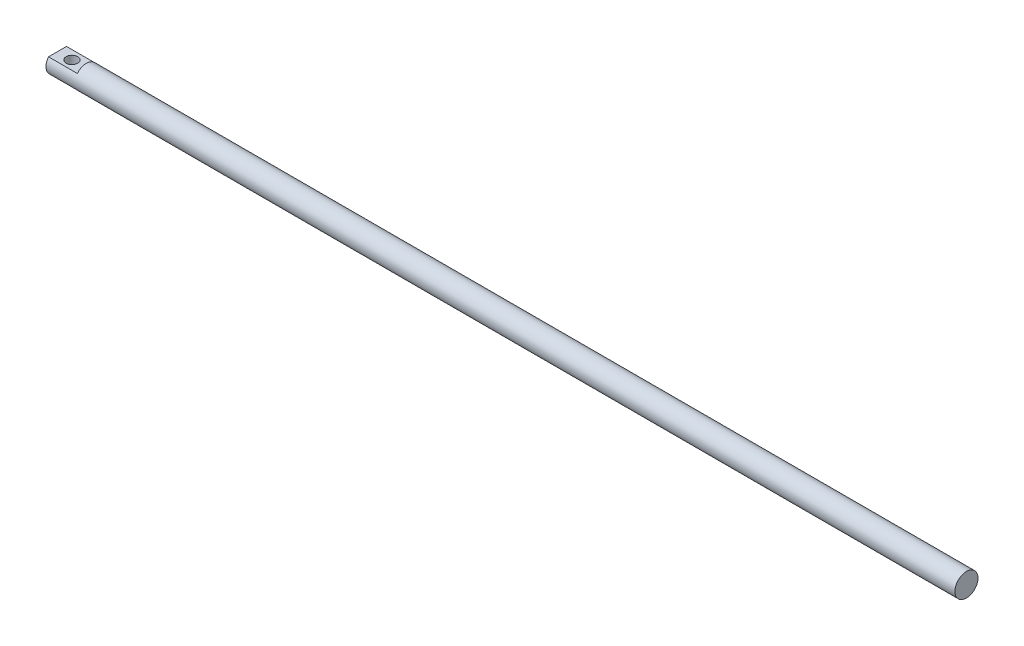
from build123d import *

# Parameters (mm, degrees)
SKETCH_1_R           = 8
EXTRUDE_1_DEPTH      = 630
SKETCH_3_OUTSIDE_W   = 144.082
SKETCH_3_OUTSIDE_H   = 144.082
SKETCH_3_OUTSIDE_W_2 = 20
SKETCH_3_OUTSIDE_H_2 = 10
CUT_EXTRUDE_2_DEPTH  = 20
SKETCH_4_R           = 4
CUT_EXTRUDE_3_DEPTH  = 14


with BuildPart() as part:
    # 草图1 → 凸台-拉伸1 (new body)
    with BuildSketch(Plane(origin=(0, 0, 0), x_dir=(0, 0, -1), z_dir=(1, 0, 0))):
        Circle(SKETCH_1_R)
    extrude(amount=EXTRUDE_1_DEPTH)

    # 草图3 outside → 切除-拉伸2 (cut)
    with BuildSketch(Plane.ZY):
        Rectangle(SKETCH_3_OUTSIDE_W, SKETCH_3_OUTSIDE_H)
        Rectangle(SKETCH_3_OUTSIDE_W_2, SKETCH_3_OUTSIDE_H_2, mode=Mode.SUBTRACT)
    extrude(amount=-CUT_EXTRUDE_2_DEPTH, mode=Mode.SUBTRACT)

    # 草图4 → 切除-拉伸3 (cut, through all)
    with BuildSketch(Plane(origin=(0, 5, 0), x_dir=(1, 0, 0), z_dir=(0, 1, 0))):
        with Locations((10, 0)):
            Circle(SKETCH_4_R)
    extrude(amount=-CUT_EXTRUDE_3_DEPTH, mode=Mode.SUBTRACT)


solid = part.part
